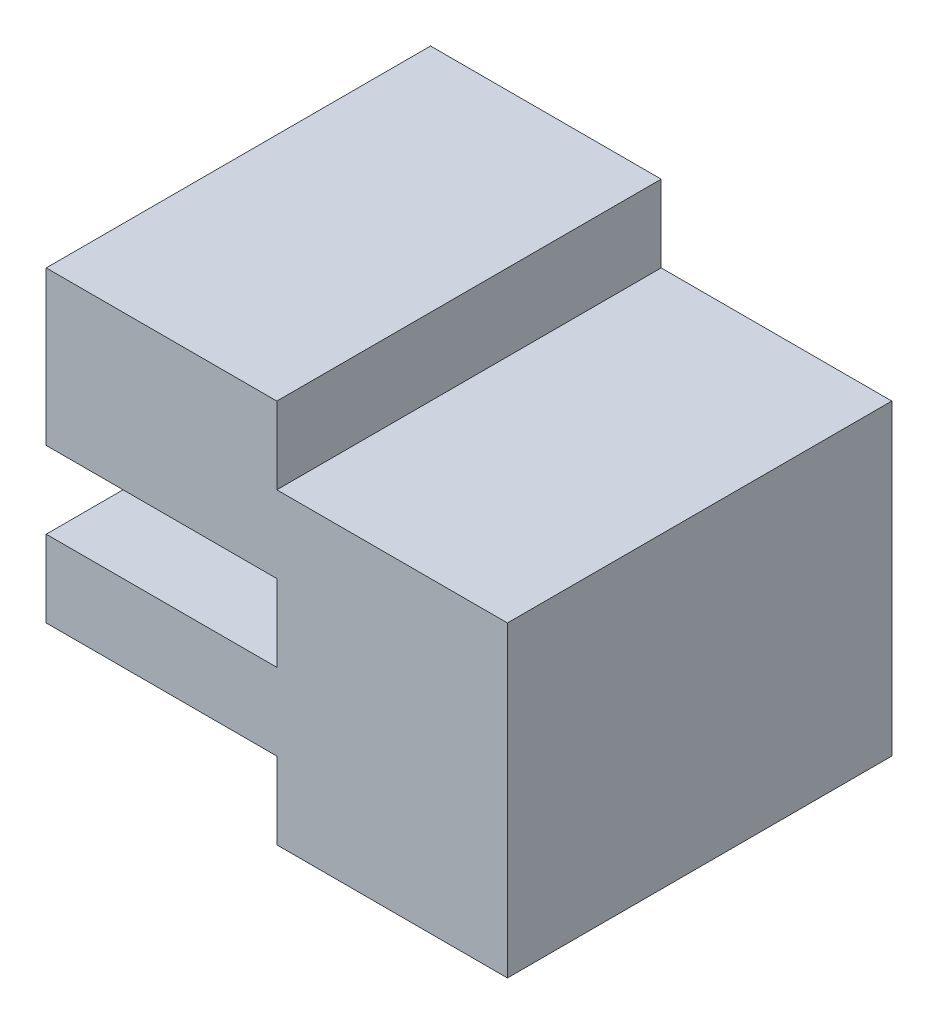
from build123d import *

# Parameters (mm, degrees)
BOSS_EXTRUDE1_DEPTH = 25


with BuildPart() as part:
    # Sketch1 → Boss-Extrude1 (new body)
    with BuildSketch(Plane.XY):
        Polygon((-30, 25), (-15, 25), (-15, 20), (0, 20), (0, 0), (-15, 0), (-15, 5), (-30, 5), (-30, 10), (-15, 10), (-15, 15), (-30, 15), align=None)
    extrude(amount=BOSS_EXTRUDE1_DEPTH)


solid = part.part
